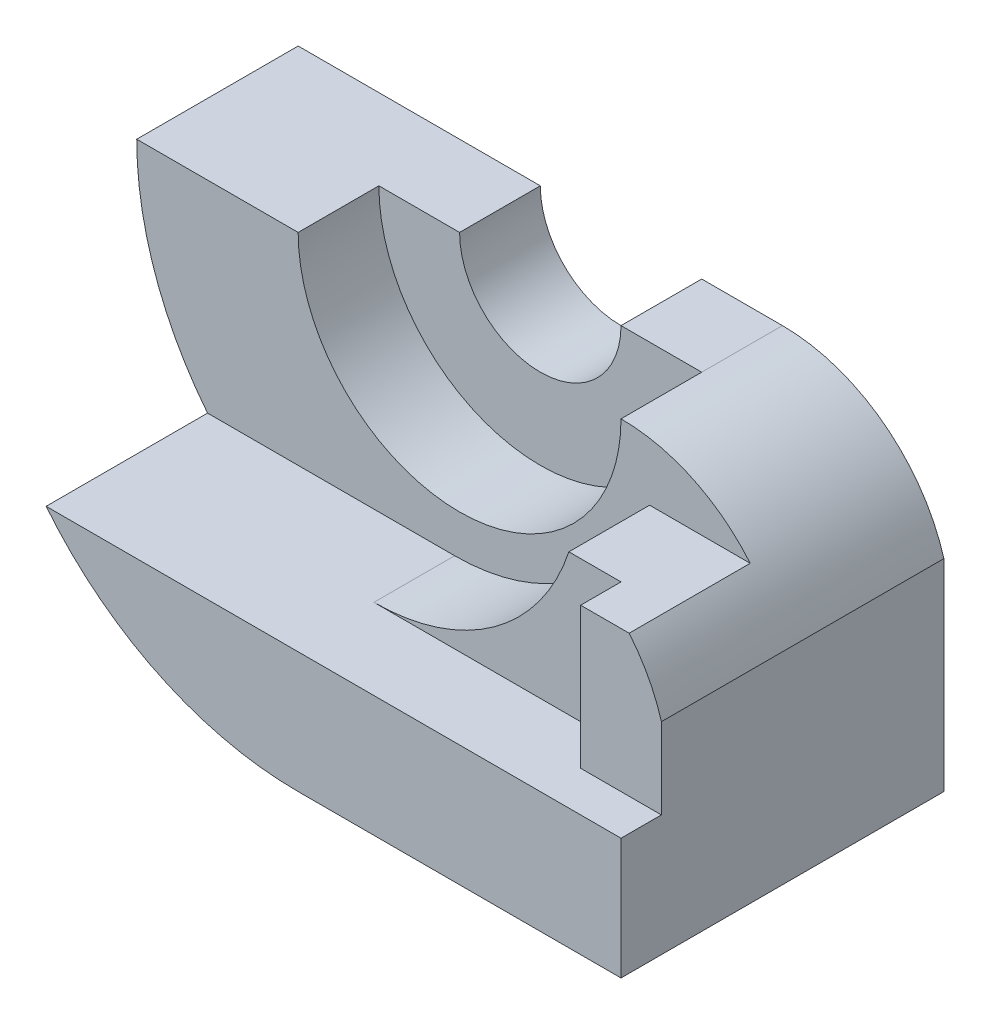
from build123d import *

# Parameters (mm, degrees)
BOSS_EXTRUDE5_DEPTH = 80
BOSS_EXTRUDE6_DEPTH = 20
SKETCH6_W           = 10
SKETCH6_H           = 50
CUT_EXTRUDE5_DEPTH  = 222
SKETCH7_W           = 30
SKETCH7_H           = 15
CUT_EXTRUDE6_DEPTH  = 222
CUT_EXTRUDE7_DEPTH  = 10
CUT_EXTRUDE8_DEPTH  = 10
BOSS_EXTRUDE9_DEPTH = 10
CUT_EXTRUDE14_DEPTH = 30


with BuildPart() as part:
    # Sketch1 → Boss-Extrude5 (new body)
    with BuildSketch(Plane.XY):
        with BuildLine():
            Line((80, -80), (80, -30))
            ThreePointArc((80, -30), (65, -8.333333333), (40, 0))
            ThreePointArc((40, 0), (0, -40), (-40, 0))
            Line((-40, 0), (-80, 0))
            ThreePointArc((-80, 0), (-56.568542495, -56.568542495), (0, -80))
            Line((0, -80), (80, -80))
        make_face()
    extrude(amount=BOSS_EXTRUDE5_DEPTH)

    # Sketch4 → Boss-Extrude6 (add)
    with BuildSketch(Plane(origin=(0, 0, 0), x_dir=(-1, 0, 0), z_dir=(0, 0, -1))):
        with BuildLine():
            Line((20, 0), (40, 0))
            ThreePointArc((40, 0), (0, -40), (-40, 0))
            Line((-40, 0), (-20, 0))
            ThreePointArc((-20, 0), (0, -20), (20, 0))
        make_face()
    extrude(amount=-BOSS_EXTRUDE6_DEPTH)

    # Sketch6 → Cut-Extrude5 (cut)
    with BuildSketch(Plane(origin=(-80, 0, 0), x_dir=(0, 0, -1), z_dir=(1, 0, 0))):
        with Locations((-75, -25)):
            Rectangle(SKETCH6_W, SKETCH6_H)
    extrude(amount=CUT_EXTRUDE5_DEPTH, mode=Mode.SUBTRACT)

    # Sketch7 → Cut-Extrude6 (cut)
    with BuildSketch(Plane(origin=(-80, 0, 0), x_dir=(0, 0, -1), z_dir=(1, 0, 0))):
        with Locations((-55, -7.5)):
            Rectangle(SKETCH7_W, SKETCH7_H)
    extrude(amount=CUT_EXTRUDE6_DEPTH, mode=Mode.SUBTRACT)

    # Sketch9 → Cut-Extrude7 (cut)
    with BuildSketch(Plane.XY.offset(70)):
        with BuildLine():
            Line((72.015621187, -15), (60, -15))
            Line((60, -15), (60, -50))
            Line((60, -50), (80, -50))
            Line((80, -50), (80, -30))
            ThreePointArc((80, -30), (76.780598469, -22.088651257), (72.015621187, -15))
        make_face()
    extrude(amount=-CUT_EXTRUDE7_DEPTH, mode=Mode.SUBTRACT)

    # Sketch10 → Cut-Extrude8 (cut)
    with BuildSketch(Plane.XY.offset(70)):
        with BuildLine():
            Line((60, -50), (60, -15))
            Line((60, -15), (47.080992435, -15))
            ThreePointArc((47.080992435, -15), (28.601457744, -40.330339745), (-1.224989992, -50))
            Line((-1.224989992, -50), (60, -50))
        make_face()
    extrude(amount=-CUT_EXTRUDE8_DEPTH, mode=Mode.SUBTRACT)

    # Sketch11 → Boss-Extrude9 (add)
    with BuildSketch(Plane.XY.offset(60)):
        with BuildLine():
            Line((60, -50), (80, -50))
            Line((80, -50), (80, -30))
            ThreePointArc((80, -30), (76.780598469, -22.088651257), (72.015621187, -15))
            Line((72.015621187, -15), (70, -15))
            Line((70, -15), (60, -15))
            Line((60, -15), (60, -50))
        make_face()
    extrude(amount=BOSS_EXTRUDE9_DEPTH)

    # Sketch15 → Cut-Extrude14 (cut)
    with BuildSketch(Plane.XY.offset(70)):
        with BuildLine():
            Line((47.080992435, -15), (37.080992435, -15))
            ThreePointArc((37.080992435, -15), (0, -40), (-37.080992435, -15))
            Line((-37.080992435, -15), (-78.581168228, -15))
            ThreePointArc((-78.581168228, -15), (-72.654636407, -33.485874761), (-62.449979984, -50))
            Line((-62.449979984, -50), (-1.224989992, -50))
            ThreePointArc((-1.224989992, -50), (28.601457744, -40.330339745), (47.080992435, -15))
        make_face()
    extrude(amount=-CUT_EXTRUDE14_DEPTH, mode=Mode.SUBTRACT)


solid = part.part
